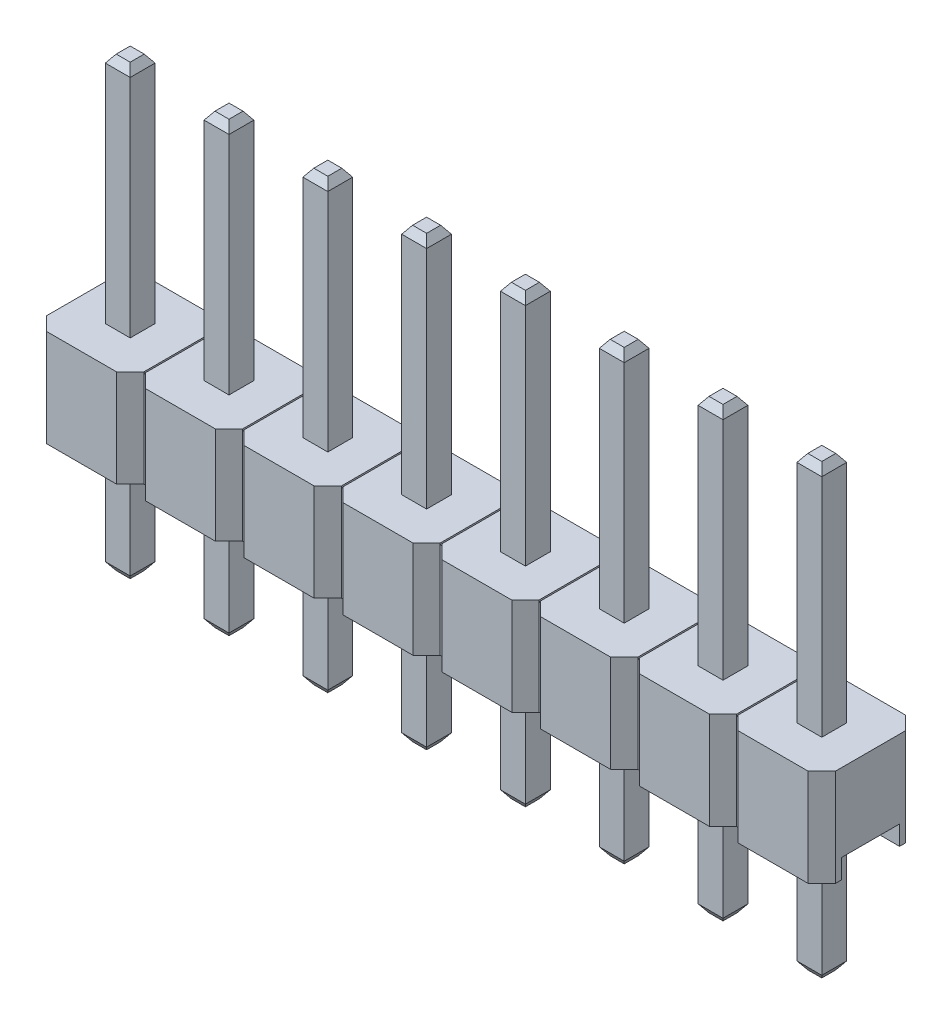
from build123d import *
from OCP.BRepFilletAPI import BRepFilletAPI_MakeChamfer

# Parameters (mm, degrees)
BOSS_EXTRUDE1_DEPTH         = 2.5
SKETCH2_W                   = 20.28
SKETCH2_H                   = 1.5
CUT_EXTRUDE1_DEPTH          = 0.5
SKETCH4_W                   = 0.04
SKETCH4_H                   = 1.8
CUT_EXTRUDE2_DEPTH          = 0.04
BOSS_EXTRUDE2_START         = -5.5
SKETCH3_W                   = 0.64
SKETCH3_H                   = 0.64
BOSS_EXTRUDE2_DEPTH         = 11.5
CHAMFER1_SIZE               = 0.2
CHAMFER1_SIZE2              = 0.140041508
LPATTERN1_COUNT             = 8
LPATTERN1_PITCH             = 2.54
CHAMFER1_OF_LPATTERN1_SIZE  = 0.2
CHAMFER1_OF_LPATTERN1_SIZE2 = 0.140041508


with BuildPart() as part:
    # Sketch1 → Boss-Extrude1 (new body)
    with BuildSketch(Plane(origin=(0, 0, 0), x_dir=(1, 0, 0), z_dir=(0, 1, 0))):
        Polygon((0, 2.15), (0.35, 2.5), (2.15, 2.5), (2.5, 2.15), (2.54, 2.15), (2.89, 2.5), (4.69, 2.5), (5.04, 2.15), (5.08, 2.15), (5.43, 2.5), (7.23, 2.5), (7.58, 2.15), (7.62, 2.15), (7.97, 2.5), (9.77, 2.5), (10.12, 2.15), (10.16, 2.15), (10.51, 2.5), (12.31, 2.5), (12.66, 2.15), (12.7, 2.15), (13.05, 2.5), (14.85, 2.5), (15.2, 2.15), (15.24, 2.15), (15.59, 2.5), (17.39, 2.5), (17.74, 2.15), (17.78, 2.15), (18.13, 2.5), (19.93, 2.5), (20.28, 2.15), (20.28, 0.35), (19.93, 0), (18.13, 0), (17.78, 0.35), (17.74, 0.35), (17.39, 0), (15.59, 0), (15.24, 0.35), (15.2, 0.35), (14.85, 0), (13.05, 0), (12.7, 0.35), (12.66, 0.35), (12.31, 0), (10.51, 0), (10.16, 0.35), (10.12, 0.35), (9.77, 0), (7.97, 0), (7.62, 0.35), (7.58, 0.35), (7.23, 0), (5.43, 0), (5.08, 0.35), (5.04, 0.35), (4.69, 0), (2.89, 0), (2.54, 0.35), (2.5, 0.35), (2.15, 0), (0.35, 0), (0, 0.35), align=None)
    extrude(amount=BOSS_EXTRUDE1_DEPTH)

    # Sketch2 → Cut-Extrude1 (cut)
    with BuildSketch(Plane.XZ):
        with Locations((10.14, -1.25)):
            Rectangle(SKETCH2_W, SKETCH2_H)
    extrude(amount=-CUT_EXTRUDE1_DEPTH, mode=Mode.SUBTRACT)

    # Sketch4 → Cut-Extrude2 (cut)
    with BuildSketch(Plane(origin=(0, 2.5, 0), x_dir=(1, 0, 0), z_dir=(0, 1, 0))):
        with Locations((5.06, 1.25)):
            Rectangle(SKETCH4_W, SKETCH4_H)
        with Locations((2.52, 1.25)):
            Rectangle(SKETCH4_W, SKETCH4_H)
        with Locations((7.6, 1.25)):
            Rectangle(SKETCH4_W, SKETCH4_H)
        with Locations((10.14, 1.25)):
            Rectangle(SKETCH4_W, SKETCH4_H)
        with Locations((12.68, 1.25)):
            Rectangle(SKETCH4_W, SKETCH4_H)
        with Locations((15.22, 1.25)):
            Rectangle(SKETCH4_W, SKETCH4_H)
        with Locations((17.76, 1.25)):
            Rectangle(SKETCH4_W, SKETCH4_H)
    extrude(amount=-CUT_EXTRUDE2_DEPTH, mode=Mode.SUBTRACT)

    # Sketch3 → Boss-Extrude2 (add)
    with BuildSketch(Plane(origin=(0, 2.5, 0), x_dir=(1, 0, 0), z_dir=(0, 1, 0)).offset(BOSS_EXTRUDE2_START)):
        with Locations((1.25, 1.25)):
            Rectangle(SKETCH3_W, SKETCH3_H)
    boss_extrude2 = extrude(amount=BOSS_EXTRUDE2_DEPTH)

    # Chamfer1: one chamfer whose edges measure the first distance from different faces: ONE call of the kernel's chamfer builder (chamfer() names one face for all edges)
    chamfer1_edges_1 = [part.edges().sort_by_distance(p)[0] for p in [
        (1.57, -3, -1.25),
    ]]
    chamfer1_side_1 = [part.faces().sort_by_distance(p)[0] for p in [
        (1.57, -1.25, -1.25),
    ]]
    chamfer1_edges_2 = [part.edges().sort_by_distance(p)[0] for p in [
        (1.25, -3, -0.93),
    ]]
    chamfer1_side_2 = [part.faces().sort_by_distance(p)[0] for p in [
        (1.25, -1.25, -0.93),
    ]]
    chamfer1_edges_3 = [part.edges().sort_by_distance(p)[0] for p in [
        (0.93, -3, -1.25),
    ]]
    chamfer1_side_3 = [part.faces().sort_by_distance(p)[0] for p in [
        (0.93, -1.25, -1.25),
    ]]
    chamfer1_edges_4 = [part.edges().sort_by_distance(p)[0] for p in [
        (1.25, -3, -1.57),
    ]]
    chamfer1_side_4 = [part.faces().sort_by_distance(p)[0] for p in [
        (1.25, -1.25, -1.57),
    ]]
    chamfer1_edges_5 = [part.edges().sort_by_distance(p)[0] for p in [
        (1.57, 8.5, -1.25),
    ]]
    chamfer1_side_5 = [part.faces().sort_by_distance(p)[0] for p in [
        (1.57, 5.5, -1.25),
    ]]
    chamfer1_edges_6 = [part.edges().sort_by_distance(p)[0] for p in [
        (1.25, 8.5, -1.57),
    ]]
    chamfer1_side_6 = [part.faces().sort_by_distance(p)[0] for p in [
        (1.25, 5.5, -1.57),
    ]]
    chamfer1_edges_7 = [part.edges().sort_by_distance(p)[0] for p in [
        (0.93, 8.5, -1.25),
    ]]
    chamfer1_side_7 = [part.faces().sort_by_distance(p)[0] for p in [
        (0.93, 5.5, -1.25),
    ]]
    chamfer1_edges_8 = [part.edges().sort_by_distance(p)[0] for p in [
        (1.25, 8.5, -0.93),
    ]]
    chamfer1_side_8 = [part.faces().sort_by_distance(p)[0] for p in [
        (1.25, 5.5, -0.93),
    ]]
    chamfer1 = BRepFilletAPI_MakeChamfer(part.part.solid().wrapped)
    for e in chamfer1_edges_1:
        chamfer1.Add(CHAMFER1_SIZE, CHAMFER1_SIZE2, e.wrapped, chamfer1_side_1[0].wrapped)  # the first distance lies on this face
    for e in chamfer1_edges_2:
        chamfer1.Add(CHAMFER1_SIZE, CHAMFER1_SIZE2, e.wrapped, chamfer1_side_2[0].wrapped)  # the first distance lies on this face
    for e in chamfer1_edges_3:
        chamfer1.Add(CHAMFER1_SIZE, CHAMFER1_SIZE2, e.wrapped, chamfer1_side_3[0].wrapped)  # the first distance lies on this face
    for e in chamfer1_edges_4:
        chamfer1.Add(CHAMFER1_SIZE, CHAMFER1_SIZE2, e.wrapped, chamfer1_side_4[0].wrapped)  # the first distance lies on this face
    for e in chamfer1_edges_5:
        chamfer1.Add(CHAMFER1_SIZE, CHAMFER1_SIZE2, e.wrapped, chamfer1_side_5[0].wrapped)  # the first distance lies on this face
    for e in chamfer1_edges_6:
        chamfer1.Add(CHAMFER1_SIZE, CHAMFER1_SIZE2, e.wrapped, chamfer1_side_6[0].wrapped)  # the first distance lies on this face
    for e in chamfer1_edges_7:
        chamfer1.Add(CHAMFER1_SIZE, CHAMFER1_SIZE2, e.wrapped, chamfer1_side_7[0].wrapped)  # the first distance lies on this face
    for e in chamfer1_edges_8:
        chamfer1.Add(CHAMFER1_SIZE, CHAMFER1_SIZE2, e.wrapped, chamfer1_side_8[0].wrapped)  # the first distance lies on this face
    add(Compound.cast(chamfer1.Shape()), mode=Mode.REPLACE)

    # LPattern1: Boss-Extrude2 ×8
    with Locations(*[(i * LPATTERN1_PITCH, 0, 0) for i in range(1, LPATTERN1_COUNT)]):
        add(boss_extrude2)

    # Chamfer1 of LPattern1: one chamfer whose edges measure the first distance from different faces: ONE call of the kernel's chamfer builder (chamfer() names one face for all edges)
    chamfer1_of_lpattern1_edges_1 = [part.edges().sort_by_distance(p)[0] for p in [
        (4.11, -3, -1.25),
    ]]
    chamfer1_of_lpattern1_side_1 = [part.faces().sort_by_distance(p)[0] for p in [
        (4.11, -1.25, -1.25),
    ]]
    chamfer1_of_lpattern1_edges_2 = [part.edges().sort_by_distance(p)[0] for p in [
        (3.79, -3, -0.93),
    ]]
    chamfer1_of_lpattern1_side_2 = [part.faces().sort_by_distance(p)[0] for p in [
        (3.79, -1.25, -0.93),
    ]]
    chamfer1_of_lpattern1_edges_3 = [part.edges().sort_by_distance(p)[0] for p in [
        (3.47, -3, -1.25),
    ]]
    chamfer1_of_lpattern1_side_3 = [part.faces().sort_by_distance(p)[0] for p in [
        (3.47, -1.25, -1.25),
    ]]
    chamfer1_of_lpattern1_edges_4 = [part.edges().sort_by_distance(p)[0] for p in [
        (3.79, -3, -1.57),
    ]]
    chamfer1_of_lpattern1_side_4 = [part.faces().sort_by_distance(p)[0] for p in [
        (3.79, -1.25, -1.57),
    ]]
    chamfer1_of_lpattern1_edges_5 = [part.edges().sort_by_distance(p)[0] for p in [
        (4.11, 8.5, -1.25),
    ]]
    chamfer1_of_lpattern1_side_5 = [part.faces().sort_by_distance(p)[0] for p in [
        (4.11, 5.5, -1.25),
    ]]
    chamfer1_of_lpattern1_edges_6 = [part.edges().sort_by_distance(p)[0] for p in [
        (3.79, 8.5, -1.57),
    ]]
    chamfer1_of_lpattern1_side_6 = [part.faces().sort_by_distance(p)[0] for p in [
        (3.79, 5.5, -1.57),
    ]]
    chamfer1_of_lpattern1_edges_7 = [part.edges().sort_by_distance(p)[0] for p in [
        (3.47, 8.5, -1.25),
    ]]
    chamfer1_of_lpattern1_side_7 = [part.faces().sort_by_distance(p)[0] for p in [
        (3.47, 5.5, -1.25),
    ]]
    chamfer1_of_lpattern1_edges_8 = [part.edges().sort_by_distance(p)[0] for p in [
        (3.79, 8.5, -0.93),
    ]]
    chamfer1_of_lpattern1_side_8 = [part.faces().sort_by_distance(p)[0] for p in [
        (3.79, 5.5, -0.93),
    ]]
    chamfer1_of_lpattern1_edges_9 = [part.edges().sort_by_distance(p)[0] for p in [
        (6.65, -3, -1.25),
    ]]
    chamfer1_of_lpattern1_side_9 = [part.faces().sort_by_distance(p)[0] for p in [
        (6.65, -1.25, -1.25),
    ]]
    chamfer1_of_lpattern1_edges_10 = [part.edges().sort_by_distance(p)[0] for p in [
        (6.33, -3, -0.93),
    ]]
    chamfer1_of_lpattern1_side_10 = [part.faces().sort_by_distance(p)[0] for p in [
        (6.33, -1.25, -0.93),
    ]]
    chamfer1_of_lpattern1_edges_11 = [part.edges().sort_by_distance(p)[0] for p in [
        (6.01, -3, -1.25),
    ]]
    chamfer1_of_lpattern1_side_11 = [part.faces().sort_by_distance(p)[0] for p in [
        (6.01, -1.25, -1.25),
    ]]
    chamfer1_of_lpattern1_edges_12 = [part.edges().sort_by_distance(p)[0] for p in [
        (6.33, -3, -1.57),
    ]]
    chamfer1_of_lpattern1_side_12 = [part.faces().sort_by_distance(p)[0] for p in [
        (6.33, -1.25, -1.57),
    ]]
    chamfer1_of_lpattern1_edges_13 = [part.edges().sort_by_distance(p)[0] for p in [
        (6.65, 8.5, -1.25),
    ]]
    chamfer1_of_lpattern1_side_13 = [part.faces().sort_by_distance(p)[0] for p in [
        (6.65, 5.5, -1.25),
    ]]
    chamfer1_of_lpattern1_edges_14 = [part.edges().sort_by_distance(p)[0] for p in [
        (6.33, 8.5, -1.57),
    ]]
    chamfer1_of_lpattern1_side_14 = [part.faces().sort_by_distance(p)[0] for p in [
        (6.33, 5.5, -1.57),
    ]]
    chamfer1_of_lpattern1_edges_15 = [part.edges().sort_by_distance(p)[0] for p in [
        (6.01, 8.5, -1.25),
    ]]
    chamfer1_of_lpattern1_side_15 = [part.faces().sort_by_distance(p)[0] for p in [
        (6.01, 5.5, -1.25),
    ]]
    chamfer1_of_lpattern1_edges_16 = [part.edges().sort_by_distance(p)[0] for p in [
        (6.33, 8.5, -0.93),
    ]]
    chamfer1_of_lpattern1_side_16 = [part.faces().sort_by_distance(p)[0] for p in [
        (6.33, 5.5, -0.93),
    ]]
    chamfer1_of_lpattern1_edges_17 = [part.edges().sort_by_distance(p)[0] for p in [
        (9.19, -3, -1.25),
    ]]
    chamfer1_of_lpattern1_side_17 = [part.faces().sort_by_distance(p)[0] for p in [
        (9.19, -1.25, -1.25),
    ]]
    chamfer1_of_lpattern1_edges_18 = [part.edges().sort_by_distance(p)[0] for p in [
        (8.87, -3, -0.93),
    ]]
    chamfer1_of_lpattern1_side_18 = [part.faces().sort_by_distance(p)[0] for p in [
        (8.87, -1.25, -0.93),
    ]]
    chamfer1_of_lpattern1_edges_19 = [part.edges().sort_by_distance(p)[0] for p in [
        (8.55, -3, -1.25),
    ]]
    chamfer1_of_lpattern1_side_19 = [part.faces().sort_by_distance(p)[0] for p in [
        (8.55, -1.25, -1.25),
    ]]
    chamfer1_of_lpattern1_edges_20 = [part.edges().sort_by_distance(p)[0] for p in [
        (8.87, -3, -1.57),
    ]]
    chamfer1_of_lpattern1_side_20 = [part.faces().sort_by_distance(p)[0] for p in [
        (8.87, -1.25, -1.57),
    ]]
    chamfer1_of_lpattern1_edges_21 = [part.edges().sort_by_distance(p)[0] for p in [
        (9.19, 8.5, -1.25),
    ]]
    chamfer1_of_lpattern1_side_21 = [part.faces().sort_by_distance(p)[0] for p in [
        (9.19, 5.5, -1.25),
    ]]
    chamfer1_of_lpattern1_edges_22 = [part.edges().sort_by_distance(p)[0] for p in [
        (8.87, 8.5, -1.57),
    ]]
    chamfer1_of_lpattern1_side_22 = [part.faces().sort_by_distance(p)[0] for p in [
        (8.87, 5.5, -1.57),
    ]]
    chamfer1_of_lpattern1_edges_23 = [part.edges().sort_by_distance(p)[0] for p in [
        (8.55, 8.5, -1.25),
    ]]
    chamfer1_of_lpattern1_side_23 = [part.faces().sort_by_distance(p)[0] for p in [
        (8.55, 5.5, -1.25),
    ]]
    chamfer1_of_lpattern1_edges_24 = [part.edges().sort_by_distance(p)[0] for p in [
        (8.87, 8.5, -0.93),
    ]]
    chamfer1_of_lpattern1_side_24 = [part.faces().sort_by_distance(p)[0] for p in [
        (8.87, 5.5, -0.93),
    ]]
    chamfer1_of_lpattern1_edges_25 = [part.edges().sort_by_distance(p)[0] for p in [
        (11.73, -3, -1.25),
    ]]
    chamfer1_of_lpattern1_side_25 = [part.faces().sort_by_distance(p)[0] for p in [
        (11.73, -1.25, -1.25),
    ]]
    chamfer1_of_lpattern1_edges_26 = [part.edges().sort_by_distance(p)[0] for p in [
        (11.41, -3, -0.93),
    ]]
    chamfer1_of_lpattern1_side_26 = [part.faces().sort_by_distance(p)[0] for p in [
        (11.41, -1.25, -0.93),
    ]]
    chamfer1_of_lpattern1_edges_27 = [part.edges().sort_by_distance(p)[0] for p in [
        (11.09, -3, -1.25),
    ]]
    chamfer1_of_lpattern1_side_27 = [part.faces().sort_by_distance(p)[0] for p in [
        (11.09, -1.25, -1.25),
    ]]
    chamfer1_of_lpattern1_edges_28 = [part.edges().sort_by_distance(p)[0] for p in [
        (11.41, -3, -1.57),
    ]]
    chamfer1_of_lpattern1_side_28 = [part.faces().sort_by_distance(p)[0] for p in [
        (11.41, -1.25, -1.57),
    ]]
    chamfer1_of_lpattern1_edges_29 = [part.edges().sort_by_distance(p)[0] for p in [
        (11.73, 8.5, -1.25),
    ]]
    chamfer1_of_lpattern1_side_29 = [part.faces().sort_by_distance(p)[0] for p in [
        (11.73, 5.5, -1.25),
    ]]
    chamfer1_of_lpattern1_edges_30 = [part.edges().sort_by_distance(p)[0] for p in [
        (11.41, 8.5, -1.57),
    ]]
    chamfer1_of_lpattern1_side_30 = [part.faces().sort_by_distance(p)[0] for p in [
        (11.41, 5.5, -1.57),
    ]]
    chamfer1_of_lpattern1_edges_31 = [part.edges().sort_by_distance(p)[0] for p in [
        (11.09, 8.5, -1.25),
    ]]
    chamfer1_of_lpattern1_side_31 = [part.faces().sort_by_distance(p)[0] for p in [
        (11.09, 5.5, -1.25),
    ]]
    chamfer1_of_lpattern1_edges_32 = [part.edges().sort_by_distance(p)[0] for p in [
        (11.41, 8.5, -0.93),
    ]]
    chamfer1_of_lpattern1_side_32 = [part.faces().sort_by_distance(p)[0] for p in [
        (11.41, 5.5, -0.93),
    ]]
    chamfer1_of_lpattern1_edges_33 = [part.edges().sort_by_distance(p)[0] for p in [
        (14.27, -3, -1.25),
    ]]
    chamfer1_of_lpattern1_side_33 = [part.faces().sort_by_distance(p)[0] for p in [
        (14.27, -1.25, -1.25),
    ]]
    chamfer1_of_lpattern1_edges_34 = [part.edges().sort_by_distance(p)[0] for p in [
        (13.95, -3, -0.93),
    ]]
    chamfer1_of_lpattern1_side_34 = [part.faces().sort_by_distance(p)[0] for p in [
        (13.95, -1.25, -0.93),
    ]]
    chamfer1_of_lpattern1_edges_35 = [part.edges().sort_by_distance(p)[0] for p in [
        (13.63, -3, -1.25),
    ]]
    chamfer1_of_lpattern1_side_35 = [part.faces().sort_by_distance(p)[0] for p in [
        (13.63, -1.25, -1.25),
    ]]
    chamfer1_of_lpattern1_edges_36 = [part.edges().sort_by_distance(p)[0] for p in [
        (13.95, -3, -1.57),
    ]]
    chamfer1_of_lpattern1_side_36 = [part.faces().sort_by_distance(p)[0] for p in [
        (13.95, -1.25, -1.57),
    ]]
    chamfer1_of_lpattern1_edges_37 = [part.edges().sort_by_distance(p)[0] for p in [
        (14.27, 8.5, -1.25),
    ]]
    chamfer1_of_lpattern1_side_37 = [part.faces().sort_by_distance(p)[0] for p in [
        (14.27, 5.5, -1.25),
    ]]
    chamfer1_of_lpattern1_edges_38 = [part.edges().sort_by_distance(p)[0] for p in [
        (13.95, 8.5, -1.57),
    ]]
    chamfer1_of_lpattern1_side_38 = [part.faces().sort_by_distance(p)[0] for p in [
        (13.95, 5.5, -1.57),
    ]]
    chamfer1_of_lpattern1_edges_39 = [part.edges().sort_by_distance(p)[0] for p in [
        (13.63, 8.5, -1.25),
    ]]
    chamfer1_of_lpattern1_side_39 = [part.faces().sort_by_distance(p)[0] for p in [
        (13.63, 5.5, -1.25),
    ]]
    chamfer1_of_lpattern1_edges_40 = [part.edges().sort_by_distance(p)[0] for p in [
        (13.95, 8.5, -0.93),
    ]]
    chamfer1_of_lpattern1_side_40 = [part.faces().sort_by_distance(p)[0] for p in [
        (13.95, 5.5, -0.93),
    ]]
    chamfer1_of_lpattern1_edges_41 = [part.edges().sort_by_distance(p)[0] for p in [
        (16.81, -3, -1.25),
    ]]
    chamfer1_of_lpattern1_side_41 = [part.faces().sort_by_distance(p)[0] for p in [
        (16.81, -1.25, -1.25),
    ]]
    chamfer1_of_lpattern1_edges_42 = [part.edges().sort_by_distance(p)[0] for p in [
        (16.49, -3, -0.93),
    ]]
    chamfer1_of_lpattern1_side_42 = [part.faces().sort_by_distance(p)[0] for p in [
        (16.49, -1.25, -0.93),
    ]]
    chamfer1_of_lpattern1_edges_43 = [part.edges().sort_by_distance(p)[0] for p in [
        (16.17, -3, -1.25),
    ]]
    chamfer1_of_lpattern1_side_43 = [part.faces().sort_by_distance(p)[0] for p in [
        (16.17, -1.25, -1.25),
    ]]
    chamfer1_of_lpattern1_edges_44 = [part.edges().sort_by_distance(p)[0] for p in [
        (16.49, -3, -1.57),
    ]]
    chamfer1_of_lpattern1_side_44 = [part.faces().sort_by_distance(p)[0] for p in [
        (16.49, -1.25, -1.57),
    ]]
    chamfer1_of_lpattern1_edges_45 = [part.edges().sort_by_distance(p)[0] for p in [
        (16.81, 8.5, -1.25),
    ]]
    chamfer1_of_lpattern1_side_45 = [part.faces().sort_by_distance(p)[0] for p in [
        (16.81, 5.5, -1.25),
    ]]
    chamfer1_of_lpattern1_edges_46 = [part.edges().sort_by_distance(p)[0] for p in [
        (16.49, 8.5, -1.57),
    ]]
    chamfer1_of_lpattern1_side_46 = [part.faces().sort_by_distance(p)[0] for p in [
        (16.49, 5.5, -1.57),
    ]]
    chamfer1_of_lpattern1_edges_47 = [part.edges().sort_by_distance(p)[0] for p in [
        (16.17, 8.5, -1.25),
    ]]
    chamfer1_of_lpattern1_side_47 = [part.faces().sort_by_distance(p)[0] for p in [
        (16.17, 5.5, -1.25),
    ]]
    chamfer1_of_lpattern1_edges_48 = [part.edges().sort_by_distance(p)[0] for p in [
        (16.49, 8.5, -0.93),
    ]]
    chamfer1_of_lpattern1_side_48 = [part.faces().sort_by_distance(p)[0] for p in [
        (16.49, 5.5, -0.93),
    ]]
    chamfer1_of_lpattern1_edges_49 = [part.edges().sort_by_distance(p)[0] for p in [
        (19.35, -3, -1.25),
    ]]
    chamfer1_of_lpattern1_side_49 = [part.faces().sort_by_distance(p)[0] for p in [
        (19.35, -1.25, -1.25),
    ]]
    chamfer1_of_lpattern1_edges_50 = [part.edges().sort_by_distance(p)[0] for p in [
        (19.03, -3, -0.93),
    ]]
    chamfer1_of_lpattern1_side_50 = [part.faces().sort_by_distance(p)[0] for p in [
        (19.03, -1.25, -0.93),
    ]]
    chamfer1_of_lpattern1_edges_51 = [part.edges().sort_by_distance(p)[0] for p in [
        (18.71, -3, -1.25),
    ]]
    chamfer1_of_lpattern1_side_51 = [part.faces().sort_by_distance(p)[0] for p in [
        (18.71, -1.25, -1.25),
    ]]
    chamfer1_of_lpattern1_edges_52 = [part.edges().sort_by_distance(p)[0] for p in [
        (19.03, -3, -1.57),
    ]]
    chamfer1_of_lpattern1_side_52 = [part.faces().sort_by_distance(p)[0] for p in [
        (19.03, -1.25, -1.57),
    ]]
    chamfer1_of_lpattern1_edges_53 = [part.edges().sort_by_distance(p)[0] for p in [
        (19.35, 8.5, -1.25),
    ]]
    chamfer1_of_lpattern1_side_53 = [part.faces().sort_by_distance(p)[0] for p in [
        (19.35, 5.5, -1.25),
    ]]
    chamfer1_of_lpattern1_edges_54 = [part.edges().sort_by_distance(p)[0] for p in [
        (19.03, 8.5, -1.57),
    ]]
    chamfer1_of_lpattern1_side_54 = [part.faces().sort_by_distance(p)[0] for p in [
        (19.03, 5.5, -1.57),
    ]]
    chamfer1_of_lpattern1_edges_55 = [part.edges().sort_by_distance(p)[0] for p in [
        (18.71, 8.5, -1.25),
    ]]
    chamfer1_of_lpattern1_side_55 = [part.faces().sort_by_distance(p)[0] for p in [
        (18.71, 5.5, -1.25),
    ]]
    chamfer1_of_lpattern1_edges_56 = [part.edges().sort_by_distance(p)[0] for p in [
        (19.03, 8.5, -0.93),
    ]]
    chamfer1_of_lpattern1_side_56 = [part.faces().sort_by_distance(p)[0] for p in [
        (19.03, 5.5, -0.93),
    ]]
    chamfer1_of_lpattern1 = BRepFilletAPI_MakeChamfer(part.part.solid().wrapped)
    for e in chamfer1_of_lpattern1_edges_1:
        chamfer1_of_lpattern1.Add(CHAMFER1_OF_LPATTERN1_SIZE, CHAMFER1_OF_LPATTERN1_SIZE2, e.wrapped, chamfer1_of_lpattern1_side_1[0].wrapped)  # the first distance lies on this face
    for e in chamfer1_of_lpattern1_edges_2:
        chamfer1_of_lpattern1.Add(CHAMFER1_OF_LPATTERN1_SIZE, CHAMFER1_OF_LPATTERN1_SIZE2, e.wrapped, chamfer1_of_lpattern1_side_2[0].wrapped)  # the first distance lies on this face
    for e in chamfer1_of_lpattern1_edges_3:
        chamfer1_of_lpattern1.Add(CHAMFER1_OF_LPATTERN1_SIZE, CHAMFER1_OF_LPATTERN1_SIZE2, e.wrapped, chamfer1_of_lpattern1_side_3[0].wrapped)  # the first distance lies on this face
    for e in chamfer1_of_lpattern1_edges_4:
        chamfer1_of_lpattern1.Add(CHAMFER1_OF_LPATTERN1_SIZE, CHAMFER1_OF_LPATTERN1_SIZE2, e.wrapped, chamfer1_of_lpattern1_side_4[0].wrapped)  # the first distance lies on this face
    for e in chamfer1_of_lpattern1_edges_5:
        chamfer1_of_lpattern1.Add(CHAMFER1_OF_LPATTERN1_SIZE, CHAMFER1_OF_LPATTERN1_SIZE2, e.wrapped, chamfer1_of_lpattern1_side_5[0].wrapped)  # the first distance lies on this face
    for e in chamfer1_of_lpattern1_edges_6:
        chamfer1_of_lpattern1.Add(CHAMFER1_OF_LPATTERN1_SIZE, CHAMFER1_OF_LPATTERN1_SIZE2, e.wrapped, chamfer1_of_lpattern1_side_6[0].wrapped)  # the first distance lies on this face
    for e in chamfer1_of_lpattern1_edges_7:
        chamfer1_of_lpattern1.Add(CHAMFER1_OF_LPATTERN1_SIZE, CHAMFER1_OF_LPATTERN1_SIZE2, e.wrapped, chamfer1_of_lpattern1_side_7[0].wrapped)  # the first distance lies on this face
    for e in chamfer1_of_lpattern1_edges_8:
        chamfer1_of_lpattern1.Add(CHAMFER1_OF_LPATTERN1_SIZE, CHAMFER1_OF_LPATTERN1_SIZE2, e.wrapped, chamfer1_of_lpattern1_side_8[0].wrapped)  # the first distance lies on this face
    for e in chamfer1_of_lpattern1_edges_9:
        chamfer1_of_lpattern1.Add(CHAMFER1_OF_LPATTERN1_SIZE, CHAMFER1_OF_LPATTERN1_SIZE2, e.wrapped, chamfer1_of_lpattern1_side_9[0].wrapped)  # the first distance lies on this face
    for e in chamfer1_of_lpattern1_edges_10:
        chamfer1_of_lpattern1.Add(CHAMFER1_OF_LPATTERN1_SIZE, CHAMFER1_OF_LPATTERN1_SIZE2, e.wrapped, chamfer1_of_lpattern1_side_10[0].wrapped)  # the first distance lies on this face
    for e in chamfer1_of_lpattern1_edges_11:
        chamfer1_of_lpattern1.Add(CHAMFER1_OF_LPATTERN1_SIZE, CHAMFER1_OF_LPATTERN1_SIZE2, e.wrapped, chamfer1_of_lpattern1_side_11[0].wrapped)  # the first distance lies on this face
    for e in chamfer1_of_lpattern1_edges_12:
        chamfer1_of_lpattern1.Add(CHAMFER1_OF_LPATTERN1_SIZE, CHAMFER1_OF_LPATTERN1_SIZE2, e.wrapped, chamfer1_of_lpattern1_side_12[0].wrapped)  # the first distance lies on this face
    for e in chamfer1_of_lpattern1_edges_13:
        chamfer1_of_lpattern1.Add(CHAMFER1_OF_LPATTERN1_SIZE, CHAMFER1_OF_LPATTERN1_SIZE2, e.wrapped, chamfer1_of_lpattern1_side_13[0].wrapped)  # the first distance lies on this face
    for e in chamfer1_of_lpattern1_edges_14:
        chamfer1_of_lpattern1.Add(CHAMFER1_OF_LPATTERN1_SIZE, CHAMFER1_OF_LPATTERN1_SIZE2, e.wrapped, chamfer1_of_lpattern1_side_14[0].wrapped)  # the first distance lies on this face
    for e in chamfer1_of_lpattern1_edges_15:
        chamfer1_of_lpattern1.Add(CHAMFER1_OF_LPATTERN1_SIZE, CHAMFER1_OF_LPATTERN1_SIZE2, e.wrapped, chamfer1_of_lpattern1_side_15[0].wrapped)  # the first distance lies on this face
    for e in chamfer1_of_lpattern1_edges_16:
        chamfer1_of_lpattern1.Add(CHAMFER1_OF_LPATTERN1_SIZE, CHAMFER1_OF_LPATTERN1_SIZE2, e.wrapped, chamfer1_of_lpattern1_side_16[0].wrapped)  # the first distance lies on this face
    for e in chamfer1_of_lpattern1_edges_17:
        chamfer1_of_lpattern1.Add(CHAMFER1_OF_LPATTERN1_SIZE, CHAMFER1_OF_LPATTERN1_SIZE2, e.wrapped, chamfer1_of_lpattern1_side_17[0].wrapped)  # the first distance lies on this face
    for e in chamfer1_of_lpattern1_edges_18:
        chamfer1_of_lpattern1.Add(CHAMFER1_OF_LPATTERN1_SIZE, CHAMFER1_OF_LPATTERN1_SIZE2, e.wrapped, chamfer1_of_lpattern1_side_18[0].wrapped)  # the first distance lies on this face
    for e in chamfer1_of_lpattern1_edges_19:
        chamfer1_of_lpattern1.Add(CHAMFER1_OF_LPATTERN1_SIZE, CHAMFER1_OF_LPATTERN1_SIZE2, e.wrapped, chamfer1_of_lpattern1_side_19[0].wrapped)  # the first distance lies on this face
    for e in chamfer1_of_lpattern1_edges_20:
        chamfer1_of_lpattern1.Add(CHAMFER1_OF_LPATTERN1_SIZE, CHAMFER1_OF_LPATTERN1_SIZE2, e.wrapped, chamfer1_of_lpattern1_side_20[0].wrapped)  # the first distance lies on this face
    for e in chamfer1_of_lpattern1_edges_21:
        chamfer1_of_lpattern1.Add(CHAMFER1_OF_LPATTERN1_SIZE, CHAMFER1_OF_LPATTERN1_SIZE2, e.wrapped, chamfer1_of_lpattern1_side_21[0].wrapped)  # the first distance lies on this face
    for e in chamfer1_of_lpattern1_edges_22:
        chamfer1_of_lpattern1.Add(CHAMFER1_OF_LPATTERN1_SIZE, CHAMFER1_OF_LPATTERN1_SIZE2, e.wrapped, chamfer1_of_lpattern1_side_22[0].wrapped)  # the first distance lies on this face
    for e in chamfer1_of_lpattern1_edges_23:
        chamfer1_of_lpattern1.Add(CHAMFER1_OF_LPATTERN1_SIZE, CHAMFER1_OF_LPATTERN1_SIZE2, e.wrapped, chamfer1_of_lpattern1_side_23[0].wrapped)  # the first distance lies on this face
    for e in chamfer1_of_lpattern1_edges_24:
        chamfer1_of_lpattern1.Add(CHAMFER1_OF_LPATTERN1_SIZE, CHAMFER1_OF_LPATTERN1_SIZE2, e.wrapped, chamfer1_of_lpattern1_side_24[0].wrapped)  # the first distance lies on this face
    for e in chamfer1_of_lpattern1_edges_25:
        chamfer1_of_lpattern1.Add(CHAMFER1_OF_LPATTERN1_SIZE, CHAMFER1_OF_LPATTERN1_SIZE2, e.wrapped, chamfer1_of_lpattern1_side_25[0].wrapped)  # the first distance lies on this face
    for e in chamfer1_of_lpattern1_edges_26:
        chamfer1_of_lpattern1.Add(CHAMFER1_OF_LPATTERN1_SIZE, CHAMFER1_OF_LPATTERN1_SIZE2, e.wrapped, chamfer1_of_lpattern1_side_26[0].wrapped)  # the first distance lies on this face
    for e in chamfer1_of_lpattern1_edges_27:
        chamfer1_of_lpattern1.Add(CHAMFER1_OF_LPATTERN1_SIZE, CHAMFER1_OF_LPATTERN1_SIZE2, e.wrapped, chamfer1_of_lpattern1_side_27[0].wrapped)  # the first distance lies on this face
    for e in chamfer1_of_lpattern1_edges_28:
        chamfer1_of_lpattern1.Add(CHAMFER1_OF_LPATTERN1_SIZE, CHAMFER1_OF_LPATTERN1_SIZE2, e.wrapped, chamfer1_of_lpattern1_side_28[0].wrapped)  # the first distance lies on this face
    for e in chamfer1_of_lpattern1_edges_29:
        chamfer1_of_lpattern1.Add(CHAMFER1_OF_LPATTERN1_SIZE, CHAMFER1_OF_LPATTERN1_SIZE2, e.wrapped, chamfer1_of_lpattern1_side_29[0].wrapped)  # the first distance lies on this face
    for e in chamfer1_of_lpattern1_edges_30:
        chamfer1_of_lpattern1.Add(CHAMFER1_OF_LPATTERN1_SIZE, CHAMFER1_OF_LPATTERN1_SIZE2, e.wrapped, chamfer1_of_lpattern1_side_30[0].wrapped)  # the first distance lies on this face
    for e in chamfer1_of_lpattern1_edges_31:
        chamfer1_of_lpattern1.Add(CHAMFER1_OF_LPATTERN1_SIZE, CHAMFER1_OF_LPATTERN1_SIZE2, e.wrapped, chamfer1_of_lpattern1_side_31[0].wrapped)  # the first distance lies on this face
    for e in chamfer1_of_lpattern1_edges_32:
        chamfer1_of_lpattern1.Add(CHAMFER1_OF_LPATTERN1_SIZE, CHAMFER1_OF_LPATTERN1_SIZE2, e.wrapped, chamfer1_of_lpattern1_side_32[0].wrapped)  # the first distance lies on this face
    for e in chamfer1_of_lpattern1_edges_33:
        chamfer1_of_lpattern1.Add(CHAMFER1_OF_LPATTERN1_SIZE, CHAMFER1_OF_LPATTERN1_SIZE2, e.wrapped, chamfer1_of_lpattern1_side_33[0].wrapped)  # the first distance lies on this face
    for e in chamfer1_of_lpattern1_edges_34:
        chamfer1_of_lpattern1.Add(CHAMFER1_OF_LPATTERN1_SIZE, CHAMFER1_OF_LPATTERN1_SIZE2, e.wrapped, chamfer1_of_lpattern1_side_34[0].wrapped)  # the first distance lies on this face
    for e in chamfer1_of_lpattern1_edges_35:
        chamfer1_of_lpattern1.Add(CHAMFER1_OF_LPATTERN1_SIZE, CHAMFER1_OF_LPATTERN1_SIZE2, e.wrapped, chamfer1_of_lpattern1_side_35[0].wrapped)  # the first distance lies on this face
    for e in chamfer1_of_lpattern1_edges_36:
        chamfer1_of_lpattern1.Add(CHAMFER1_OF_LPATTERN1_SIZE, CHAMFER1_OF_LPATTERN1_SIZE2, e.wrapped, chamfer1_of_lpattern1_side_36[0].wrapped)  # the first distance lies on this face
    for e in chamfer1_of_lpattern1_edges_37:
        chamfer1_of_lpattern1.Add(CHAMFER1_OF_LPATTERN1_SIZE, CHAMFER1_OF_LPATTERN1_SIZE2, e.wrapped, chamfer1_of_lpattern1_side_37[0].wrapped)  # the first distance lies on this face
    for e in chamfer1_of_lpattern1_edges_38:
        chamfer1_of_lpattern1.Add(CHAMFER1_OF_LPATTERN1_SIZE, CHAMFER1_OF_LPATTERN1_SIZE2, e.wrapped, chamfer1_of_lpattern1_side_38[0].wrapped)  # the first distance lies on this face
    for e in chamfer1_of_lpattern1_edges_39:
        chamfer1_of_lpattern1.Add(CHAMFER1_OF_LPATTERN1_SIZE, CHAMFER1_OF_LPATTERN1_SIZE2, e.wrapped, chamfer1_of_lpattern1_side_39[0].wrapped)  # the first distance lies on this face
    for e in chamfer1_of_lpattern1_edges_40:
        chamfer1_of_lpattern1.Add(CHAMFER1_OF_LPATTERN1_SIZE, CHAMFER1_OF_LPATTERN1_SIZE2, e.wrapped, chamfer1_of_lpattern1_side_40[0].wrapped)  # the first distance lies on this face
    for e in chamfer1_of_lpattern1_edges_41:
        chamfer1_of_lpattern1.Add(CHAMFER1_OF_LPATTERN1_SIZE, CHAMFER1_OF_LPATTERN1_SIZE2, e.wrapped, chamfer1_of_lpattern1_side_41[0].wrapped)  # the first distance lies on this face
    for e in chamfer1_of_lpattern1_edges_42:
        chamfer1_of_lpattern1.Add(CHAMFER1_OF_LPATTERN1_SIZE, CHAMFER1_OF_LPATTERN1_SIZE2, e.wrapped, chamfer1_of_lpattern1_side_42[0].wrapped)  # the first distance lies on this face
    for e in chamfer1_of_lpattern1_edges_43:
        chamfer1_of_lpattern1.Add(CHAMFER1_OF_LPATTERN1_SIZE, CHAMFER1_OF_LPATTERN1_SIZE2, e.wrapped, chamfer1_of_lpattern1_side_43[0].wrapped)  # the first distance lies on this face
    for e in chamfer1_of_lpattern1_edges_44:
        chamfer1_of_lpattern1.Add(CHAMFER1_OF_LPATTERN1_SIZE, CHAMFER1_OF_LPATTERN1_SIZE2, e.wrapped, chamfer1_of_lpattern1_side_44[0].wrapped)  # the first distance lies on this face
    for e in chamfer1_of_lpattern1_edges_45:
        chamfer1_of_lpattern1.Add(CHAMFER1_OF_LPATTERN1_SIZE, CHAMFER1_OF_LPATTERN1_SIZE2, e.wrapped, chamfer1_of_lpattern1_side_45[0].wrapped)  # the first distance lies on this face
    for e in chamfer1_of_lpattern1_edges_46:
        chamfer1_of_lpattern1.Add(CHAMFER1_OF_LPATTERN1_SIZE, CHAMFER1_OF_LPATTERN1_SIZE2, e.wrapped, chamfer1_of_lpattern1_side_46[0].wrapped)  # the first distance lies on this face
    for e in chamfer1_of_lpattern1_edges_47:
        chamfer1_of_lpattern1.Add(CHAMFER1_OF_LPATTERN1_SIZE, CHAMFER1_OF_LPATTERN1_SIZE2, e.wrapped, chamfer1_of_lpattern1_side_47[0].wrapped)  # the first distance lies on this face
    for e in chamfer1_of_lpattern1_edges_48:
        chamfer1_of_lpattern1.Add(CHAMFER1_OF_LPATTERN1_SIZE, CHAMFER1_OF_LPATTERN1_SIZE2, e.wrapped, chamfer1_of_lpattern1_side_48[0].wrapped)  # the first distance lies on this face
    for e in chamfer1_of_lpattern1_edges_49:
        chamfer1_of_lpattern1.Add(CHAMFER1_OF_LPATTERN1_SIZE, CHAMFER1_OF_LPATTERN1_SIZE2, e.wrapped, chamfer1_of_lpattern1_side_49[0].wrapped)  # the first distance lies on this face
    for e in chamfer1_of_lpattern1_edges_50:
        chamfer1_of_lpattern1.Add(CHAMFER1_OF_LPATTERN1_SIZE, CHAMFER1_OF_LPATTERN1_SIZE2, e.wrapped, chamfer1_of_lpattern1_side_50[0].wrapped)  # the first distance lies on this face
    for e in chamfer1_of_lpattern1_edges_51:
        chamfer1_of_lpattern1.Add(CHAMFER1_OF_LPATTERN1_SIZE, CHAMFER1_OF_LPATTERN1_SIZE2, e.wrapped, chamfer1_of_lpattern1_side_51[0].wrapped)  # the first distance lies on this face
    for e in chamfer1_of_lpattern1_edges_52:
        chamfer1_of_lpattern1.Add(CHAMFER1_OF_LPATTERN1_SIZE, CHAMFER1_OF_LPATTERN1_SIZE2, e.wrapped, chamfer1_of_lpattern1_side_52[0].wrapped)  # the first distance lies on this face
    for e in chamfer1_of_lpattern1_edges_53:
        chamfer1_of_lpattern1.Add(CHAMFER1_OF_LPATTERN1_SIZE, CHAMFER1_OF_LPATTERN1_SIZE2, e.wrapped, chamfer1_of_lpattern1_side_53[0].wrapped)  # the first distance lies on this face
    for e in chamfer1_of_lpattern1_edges_54:
        chamfer1_of_lpattern1.Add(CHAMFER1_OF_LPATTERN1_SIZE, CHAMFER1_OF_LPATTERN1_SIZE2, e.wrapped, chamfer1_of_lpattern1_side_54[0].wrapped)  # the first distance lies on this face
    for e in chamfer1_of_lpattern1_edges_55:
        chamfer1_of_lpattern1.Add(CHAMFER1_OF_LPATTERN1_SIZE, CHAMFER1_OF_LPATTERN1_SIZE2, e.wrapped, chamfer1_of_lpattern1_side_55[0].wrapped)  # the first distance lies on this face
    for e in chamfer1_of_lpattern1_edges_56:
        chamfer1_of_lpattern1.Add(CHAMFER1_OF_LPATTERN1_SIZE, CHAMFER1_OF_LPATTERN1_SIZE2, e.wrapped, chamfer1_of_lpattern1_side_56[0].wrapped)  # the first distance lies on this face
    add(Compound.cast(chamfer1_of_lpattern1.Shape()), mode=Mode.REPLACE)


solid = part.part
